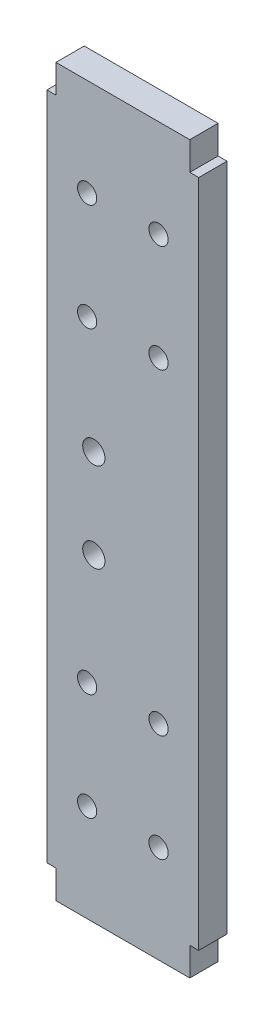
from build123d import *

# Parameters (mm, degrees)
SKETCH1_W              = 34
SKETCH1_H              = 150
BOSS_EXTRUDE1_DEPTH    = 6.35
SKETCH3_W              = 30
SKETCH3_H              = 6.35
BOSS_EXTRUDE2_DEPTH    = 6.35
F_8_CLEARANCE_HOLE1_D  = 4.3053
F_10_CLEARANCE_HOLE1_D = 4.9784


with BuildPart() as part:
    # Sketch1 → Boss-Extrude1 (new body)
    with BuildSketch(Plane.XY):
        Rectangle(SKETCH1_W, SKETCH1_H)
    extrude(amount=BOSS_EXTRUDE1_DEPTH)

    # Sketch3 → Boss-Extrude2 (add)
    with BuildSketch(Plane.XY.offset(6.35)):
        with Locations((0, 78.175)):
            Rectangle(SKETCH3_W, SKETCH3_H)
        with Locations((0, -78.175)):
            Rectangle(SKETCH3_W, SKETCH3_H)
    extrude(amount=-BOSS_EXTRUDE2_DEPTH)

    # #8 Clearance Hole1 (through all)
    with Locations(Plane.XY.offset(6.35)):
        with Locations((-8, 59.5), (8, 59.5), (8, 35.5), (-8, 35.5), (-8, -35.5), (-8, -59.5), (8, -59.5), (8, -35.5)):
            Hole(F_8_CLEARANCE_HOLE1_D / 2)

    # #10 Clearance Hole1 (through all)
    with Locations(Plane.XY.offset(6.35)):
        with Locations((-6.5, 10), (-6.5, -10)):
            Hole(F_10_CLEARANCE_HOLE1_D / 2)


solid = part.part
